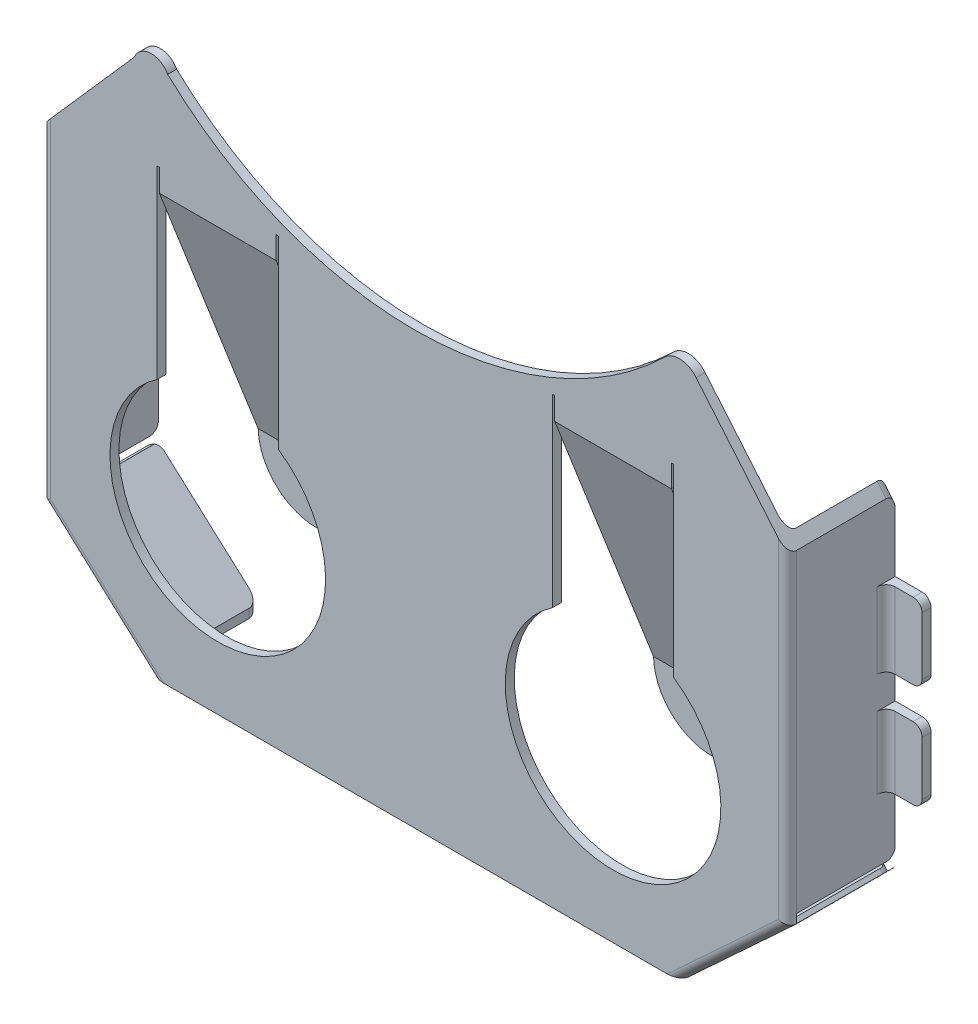
from build123d import *

# Parameters (mm, degrees)
BOSS_EXTRUDE1_DEPTH     = 3.048
SKETCH2_R               = 3.048
CUT_EXTRUDE1_DEPTH      = 4.048
CUT_EXTRUDE1_DEPTH_BACK = 1
SKETCH4_W               = 1.016
SKETCH4_H               = 2.032
SKETCH4_H_2             = 2.140270597
BOSS_EXTRUDE2_DEPTH     = 0.254
FILLET1_R               = 0.254
FILLET2_R               = 0.254
CUT_EXTRUDE3_DEPTH      = 2.794
FILLET4_R               = 0.254
FILLET5_R               = 0.254
SKETCH5_W               = 14.986
SKETCH5_H               = 2.794
CUT_EXTRUDE4_DEPTH      = 0.254
FILLET6_R               = 0.254
FILLET7_R               = 0.254
SKETCH9_W               = 2.794
SKETCH9_H               = 0.250785097
CUT_EXTRUDE16_DEPTH     = 22.867195958
SKETCH11_W              = 0.146811333
SKETCH11_H              = 2.794
CUT_EXTRUDE17_DEPTH     = 0.1524
SKETCH12_W              = 0.127
SKETCH12_H              = 2.794
CUT_EXTRUDE18_DEPTH     = 0.127
FILLET8_R               = 0.254
FILLET9_R               = 0.254
CUT_EXTRUDE19_DEPTH     = 4.048
SKETCH14_W              = 0.0635
SKETCH14_H              = 0.635
CUT_EXTRUDE20_DEPTH     = 4.048
BOSS_EXTRUDE3_DEPTH     = 0.254
BOSS_EXTRUDE3_2_DEPTH   = 0.254
EXTRUDE_THIN1_START     = 5.498846
EXTRUDE_THIN1_DEPTH     = 1.651
EXTRUDE_THIN2_START     = -5.678678
EXTRUDE_THIN2_DEPTH     = 1.651


with BuildPart() as part:
    # Sketch1 → Boss-Extrude1 (new body)
    with BuildSketch(Plane.XY):
        with BuildLine():
            Line((-0.851262648, 0), (14.134737352, 0))
            Line((14.134737352, 0), (17.156597979, 2.794))
            Line((17.156597979, 2.794), (17.156597979, 11.938))
            Line((17.156597979, 11.938), (14.577867285, 15.006547395))
            ThreePointArc((14.577867285, 15.006547395), (14.134737352, 15.237403744), (13.671405467, 15.050368039))
            ThreePointArc((13.671405467, 15.050368039), (6.67167938, 12.198054113), (-0.3622948, 14.964833333))
            ThreePointArc((-0.3622948, 14.964833333), (-0.851262648, 15.239214076), (-1.307252485, 14.912950968))
            Line((-1.307252485, 14.912950968), (-3.925402021, 11.938))
            Line((-3.925402021, 11.938), (-3.925402021, 2.794))
            Line((-3.925402021, 2.794), (-0.851262648, 0))
        make_face()
    extrude(amount=BOSS_EXTRUDE1_DEPTH)

    # Sketch2 → Cut-Extrude1 (cut, two sides)
    with BuildSketch(Plane.XY) as cut_extrude1_sk:
        with Locations((1.053737352, 4.826)):
            Circle(SKETCH2_R)
        with Locations((12.229737352, 4.826)):
            Circle(SKETCH2_R)
    extrude(amount=CUT_EXTRUDE1_DEPTH, mode=Mode.SUBTRACT)
    extrude(cut_extrude1_sk.sketch, amount=-CUT_EXTRUDE1_DEPTH_BACK, mode=Mode.SUBTRACT)

    # Sketch4 → Boss-Extrude2 (add)
    with BuildSketch(Plane.XY):
        with Locations((17.664597979, 5.842)):
            Rectangle(SKETCH4_W, SKETCH4_H)
        with Locations((17.664597979, 8.835864702)):
            Rectangle(SKETCH4_W, SKETCH4_H_2)
    boss_extrude2 = extrude(amount=BOSS_EXTRUDE2_DEPTH)

    # Fillet1
    fillet1_edges = [part.edges().sort_by_distance(p)[0] for p in [
        (17.156597979, 8.835864702, 0.254),
        (17.156597979, 5.842, 0.254),
    ]]
    fillet(fillet1_edges, radius=FILLET1_R)

    # Fillet2
    fillet2_edges = [part.edges().sort_by_distance(p)[0] for p in [
        (18.172597979, 9.906, 0.127),
        (18.172597979, 7.765729403, 0.127),
        (18.172597979, 4.826, 0.127),
        (18.172597979, 6.858, 0.127),
    ]]
    fillet(fillet2_edges, radius=FILLET2_R)

    # Sketch3 → Cut-Extrude3 (cut)
    with BuildSketch(Plane.XY):
        Polygon((-3.671402021, 11.938), (-3.671402021, 17.481090956), (16.902597979, 17.481090956), (16.902597979, 11.938), (16.902597979, 2.794), (14.134737352, 0.254), (-0.851262648, 0.254), (-3.671402021, 2.794), align=None)
    extrude(amount=CUT_EXTRUDE3_DEPTH, mode=Mode.SUBTRACT)

    # Mirror3: Boss-Extrude2 across plane
    add(boss_extrude2.mirror(Plane(origin=(6.731, 0, 0), x_dir=(0, 0, 1), z_dir=(1, 0, 0))))

    # Fillet4
    fillet4_edges = [part.edges().sort_by_distance(p)[0] for p in [
        (-3.925402021, 8.835864702, 0.254),
        (-3.925402021, 5.842, 0.254),
    ]]
    fillet(fillet4_edges, radius=FILLET4_R)

    # Fillet5
    fillet5_edges = [part.edges().sort_by_distance(p)[0] for p in [
        (-4.710597979, 9.906, 0.127),
        (-4.710597979, 7.765729403, 0.127),
        (-4.710597979, 6.858, 0.127),
        (-4.710597979, 4.826, 0.127),
    ]]
    fillet(fillet5_edges, radius=FILLET5_R)

    # Sketch5 → Cut-Extrude4 (cut)
    with BuildSketch(Plane(origin=(0, 0, 0), x_dir=(-1, 0, 0), z_dir=(0, -1, 0))):
        with Locations((-6.641737352, -1.397)):
            Rectangle(SKETCH5_W, SKETCH5_H)
    extrude(amount=-CUT_EXTRUDE4_DEPTH, mode=Mode.SUBTRACT)

    # Fillet6
    fillet6_edges = [part.edges().sort_by_distance(p)[0] for p in [
        (-0.851262648, 0.127, 0),
        (-0.851262648, 0.127, 2.794),
        (14.134737352, 0.127, 2.794),
        (14.134737352, 0.127, 0),
    ]]
    fillet(fillet6_edges, radius=FILLET6_R)

    # Fillet7
    fillet7_edges = [part.edges().sort_by_distance(p)[0] for p in [
        (-3.798402021, 12.082307561, 0),
        (16.902597979, 7.517123, 2.794),
        (-3.671402021, 7.510307561, 2.794),
        (17.029597979, 12.089123, 0),
        (-3.925402021, 7.366, 3.048),
        (-2.388332334, 1.397, 3.048),
        (15.645667666, 1.397, 3.048),
        (17.156597979, 7.366, 3.048),
    ]]
    fillet(fillet7_edges, radius=FILLET7_R)

    # Sketch9 → Cut-Extrude16 (cut, through all)
    with BuildSketch(Plane(origin=(17.156597979, 0, 0), x_dir=(0, 0, -1), z_dir=(1, 0, 0))):
        with Locations((-1.397, 2.921932549)):
            Rectangle(SKETCH9_W, SKETCH9_H)
    extrude(amount=-CUT_EXTRUDE16_DEPTH, mode=Mode.SUBTRACT)

    # Sketch11 → Cut-Extrude17 (cut)
    with BuildSketch(Plane(origin=(-0.385085263, -0.423695694, 0), x_dir=(-0.740020604, 0.672584199, 0), z_dir=(-0.672584199, -0.740020604, 0))):
        with Locations((4.710672963, -1.397)):
            Rectangle(SKETCH11_W, SKETCH11_H)
    extrude(amount=-CUT_EXTRUDE17_DEPTH, mode=Mode.SUBTRACT)

    # Sketch12 → Cut-Extrude18 (cut)
    with BuildSketch(Plane(origin=(6.51443008, -7.045704998, 0), x_dir=(-0.734247321, -0.678882075, 0), z_dir=(0.678882075, -0.734247321, 0))):
        with Locations((-14.430482615, -1.397)):
            Rectangle(SKETCH12_W, SKETCH12_H)
    extrude(amount=-CUT_EXTRUDE18_DEPTH, mode=Mode.SUBTRACT)

    # Fillet8
    fillet8_edges = [part.edges().sort_by_distance(p)[0] for p in [
        (-3.770731963, 2.745898509, 0),
        (17.022315916, 2.752160988, 0),
    ]]
    fillet(fillet8_edges, radius=FILLET8_R)

    # Fillet9
    fillet9_edges = [part.edges().sort_by_distance(p)[0] for p in [
        (17.029597979, 3.047325097, 0),
        (-3.798402021, 3.047325097, 0),
    ]]
    fillet(fillet9_edges, radius=FILLET9_R)

    # Sketch13 → Cut-Extrude19 (cut, through all)
    with BuildSketch(Plane.XY):
        Polygon((-0.597262648, 11.938), (2.704737352, 11.938), (2.768237352, 11.938), (2.768237352, 4.826), (2.704737352, 4.826), (-0.597262648, 4.826), (-0.660762648, 4.826), (-0.660762648, 11.938), align=None)
        Polygon((10.578737352, 4.826), (10.515237352, 4.826), (10.515237352, 11.938), (10.578737352, 11.938), (13.880737352, 11.938), (13.944237352, 11.938), (13.944237352, 4.826), (13.880737352, 4.826), align=None)
    extrude(amount=CUT_EXTRUDE19_DEPTH, mode=Mode.SUBTRACT)

    # Sketch14 → Cut-Extrude20 (cut, through all)
    with BuildSketch(Plane.XY):
        with Locations((10.546987352, 12.2555)):
            Rectangle(SKETCH14_W, SKETCH14_H)
        with Locations((13.912487352, 12.2555)):
            Rectangle(SKETCH14_W, SKETCH14_H)
        with Locations((-0.629012648, 12.2555)):
            Rectangle(SKETCH14_W, SKETCH14_H)
        with Locations((2.736487352, 12.2555)):
            Rectangle(SKETCH14_W, SKETCH14_H)
    extrude(amount=CUT_EXTRUDE20_DEPTH, mode=Mode.SUBTRACT)



with BuildPart() as body_2:
    # Sketch15 → Boss-Extrude3 (new body)
    with BuildSketch(Plane.XY):
        with BuildLine():
            Line((-0.597262648, 4.826), (2.704737352, 4.826))
            ThreePointArc((2.704737352, 4.826), (1.053737352, 3.175), (-0.597262648, 4.826))
        make_face()
    extrude(amount=BOSS_EXTRUDE3_DEPTH)


with BuildPart() as body_3:
    # Sketch15 → Boss-Extrude3 2 (new body)
    with BuildSketch(Plane.XY):
        with BuildLine():
            Line((10.578737352, 4.826), (13.880737352, 4.826))
            ThreePointArc((13.880737352, 4.826), (12.229737352, 3.175), (10.578737352, 4.826))
        make_face()
    extrude(amount=BOSS_EXTRUDE3_2_DEPTH)

    # Sketch18 → Extrude-Thin1 (add, symmetric)
    with BuildSketch(Plane(origin=(6.731, 0, 0), x_dir=(0, 0, -1), z_dir=(1, 0, 0)).offset(EXTRUDE_THIN1_START)):
        Polygon((-3.045381953, 11.934244374), (-0.234911746, 4.736954124), (0.001689241, 4.829344454), (-2.808780967, 12.026634704), align=None)
    extrude(amount=EXTRUDE_THIN1_DEPTH, both=True)


with BuildPart() as part_1:
    add(part.part)

    add(body_2.part)  # Extrude-Thin2 merges body 2
    # Sketch20 → Extrude-Thin2 (add, symmetric)
    with BuildSketch(Plane(origin=(6.731, 0, 0), x_dir=(0, 0, -1), z_dir=(1, 0, 0)).offset(EXTRUDE_THIN2_START)):
        Polygon((-2.810163669, 12.030938012), (0, 4.825202854), (-0.236641069, 4.732915236), (-3.046804738, 11.938650394), align=None)
    extrude(amount=EXTRUDE_THIN2_DEPTH, both=True)


solid = Compound([body_3.part, part_1.part])
